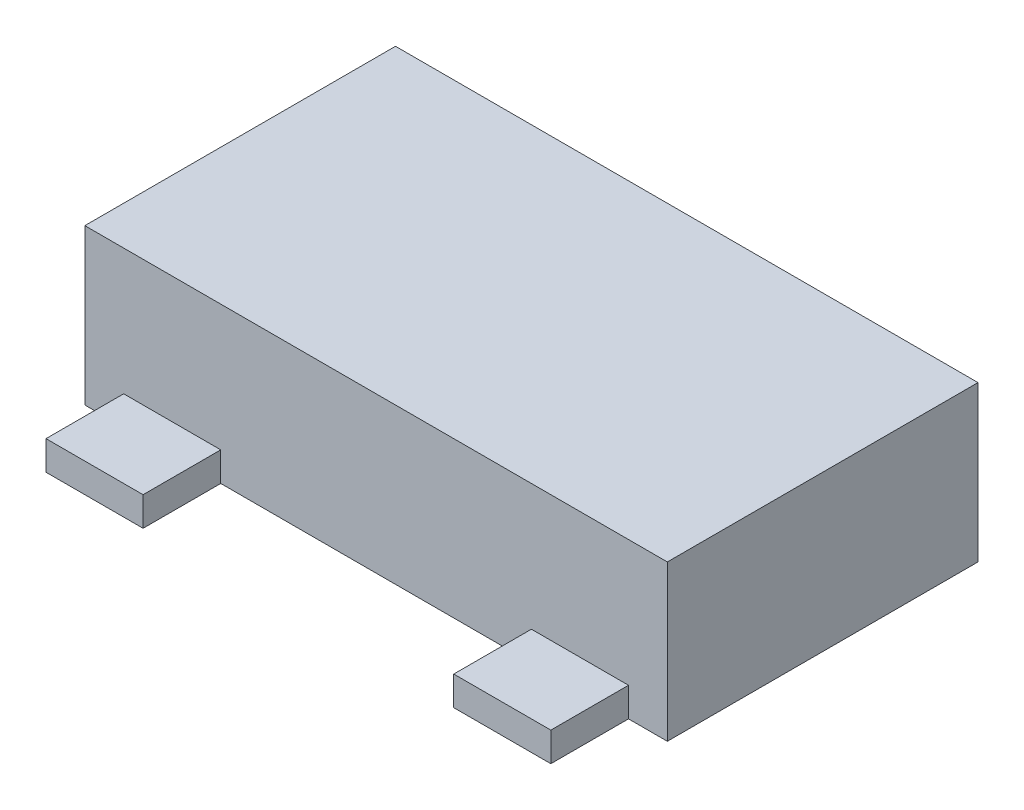
from build123d import *

# Parameters (mm, degrees)
BASES_W       = 3
BASES_H       = 1.6
BASE_DEPTH    = 0.8
LEGS_W        = 0.5
LEGS_H        = 0.4
LEG_DEPTH     = 0.15
SIDELEGS_W    = 0.5
SIDELEGS_H    = 0.4
SIDELEG_DEPTH = 0.15


with BuildPart() as part:
    # BaseS → Base (new body)
    with BuildSketch(Plane(origin=(0, 0, 0), x_dir=(1, 0, 0), z_dir=(0, 1, 0))):
        Rectangle(BASES_W, BASES_H)
    extrude(amount=BASE_DEPTH)

    # LegS → Leg (add)
    with BuildSketch(Plane(origin=(0, 0, 0), x_dir=(1, 0, 0), z_dir=(0, 1, 0))):
        with Locations((0, 1)):
            Rectangle(LEGS_W, LEGS_H)
    extrude(amount=LEG_DEPTH)

    # SideLegS → SideLeg (add)
    with BuildSketch(Plane(origin=(0, 0, 0), x_dir=(1, 0, 0), z_dir=(0, 1, 0))):
        with Locations((-1.05, -1)):
            Rectangle(SIDELEGS_W, SIDELEGS_H)
    sideleg = extrude(amount=SIDELEG_DEPTH)

    # SLHM: SideLeg across plane
    add(sideleg.mirror(Plane(origin=(0, 0, 0), x_dir=(0, 0, 1), z_dir=(1, 0, 0))))


solid = part.part
